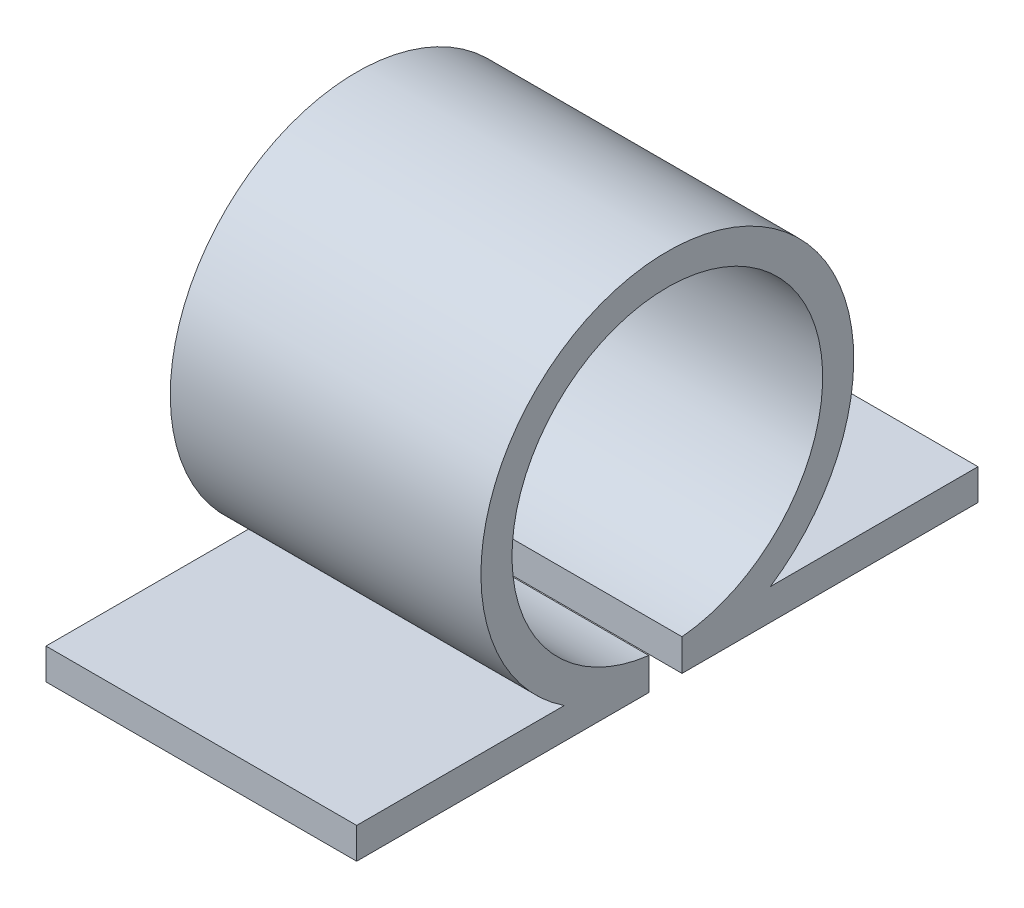
from build123d import *

# Parameters (mm, degrees)
BOSS_EXTRUDE1_DEPTH = 10


with BuildPart() as part:
    # Sketch1 → Boss-Extrude1 (new body)
    with BuildSketch(Plane(origin=(0, 0, 0), x_dir=(0, 0, -1), z_dir=(1, 0, 0))):
        with BuildLine():
            Line((10, -5), (3.31662479, -5))
            ThreePointArc((3.31662479, -5), (0, 6), (-3.31662479, -5))
            Line((-3.31662479, -5), (-10, -5))
            Line((-10, -5), (-10, -6))
            Line((-10, -6), (-0.597061761, -6))
            Line((-0.597061761, -6), (-0.597061761, -4.964223731))
            ThreePointArc((-0.597061761, -4.964223731), (0.062391283, 4.999610718), (0.472995759, -4.977577223))
            Line((0.472995759, -4.977577223), (0.472995759, -6))
            Line((0.472995759, -6), (10, -6))
            Line((10, -6), (10, -5))
        make_face()
    extrude(amount=BOSS_EXTRUDE1_DEPTH)


solid = part.part
